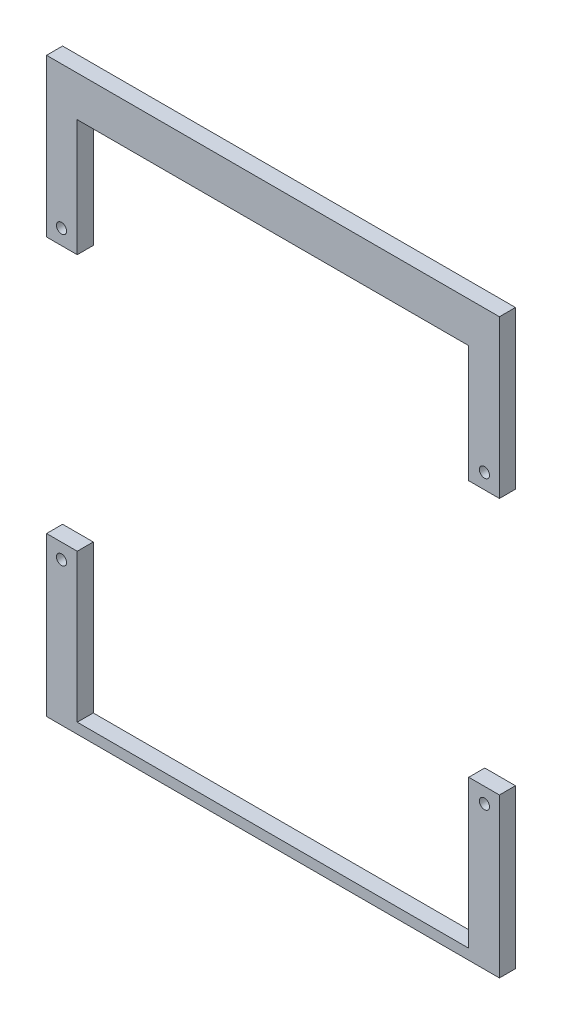
from build123d import *

# Parameters (mm, degrees)
SKETCH1_R               = 2
REPEATING_FRAME_DEPTH   = 6.35
REPEATING_FRAME_2_DEPTH = 6.35


with BuildPart() as part:
    # Sketch1 → Repeating Frame (new body)
    with BuildSketch(Plane.XY):
        Polygon((-89.6514, -107.43), (0, -107.43), (0, -103.3), (-77.5, -103.3), (-77.5, -44.6724), (-89.6514, -44.6724), align=None)
        with Locations((-83.72, -50.6724)):
            Circle(SKETCH1_R, mode=Mode.SUBTRACT)
    repeating_frame = extrude(amount=REPEATING_FRAME_DEPTH)


with BuildPart() as body_2:
    # Sketch1 → Repeating Frame 2 (new body)
    with BuildSketch(Plane.XY):
        Polygon((-77.5, 103.3), (0, 103.3), (0, 119.3), (-89.6514, 119.3), (-89.6514, 56.98), (-77.5, 56.98), align=None)
        with Locations((-83.72, 62.98)):
            Circle(SKETCH1_R, mode=Mode.SUBTRACT)
    repeating_frame_2 = extrude(amount=REPEATING_FRAME_2_DEPTH)


with BuildPart() as part_1:
    add(part.part)

    add(body_2.part)  # Mirror1 merges body 2
    # Mirror1: Repeating Frame, Repeating Frame 2 across plane
    add(repeating_frame.mirror(Plane(origin=(0, 0, 0), x_dir=(0, 0, 1), z_dir=(1, 0, 0))))
    add(repeating_frame_2.mirror(Plane(origin=(0, 0, 0), x_dir=(0, 0, 1), z_dir=(1, 0, 0))))


solid = part_1.part
